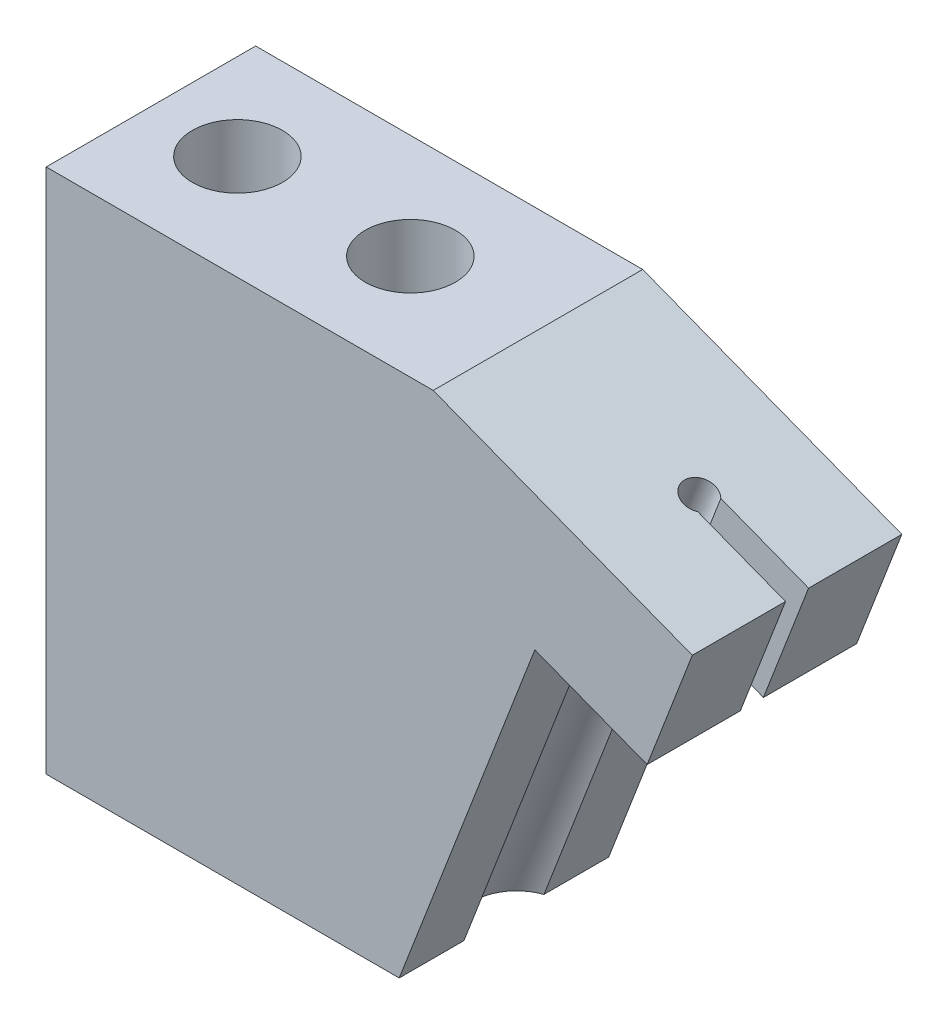
from build123d import *

# Parameters (mm, degrees)
BASE_EXTRUDE_DEPTH                 = 5
CUTAWAY_FOR_CLAMP_PLATE_WIRE_DEPTH = 11
HOLES_TO_PITCH_PLATE_REACH         = 22
SKETCH4_R                          = 2.15265
SKETCH5_R                          = 2.05
EXTRUDE1_DEPTH                     = 4
SKETCH6_R                          = 0.75
EXTRUDE2_DEPTH                     = 2
SKETCH8_W                          = 18.476012794
SKETCH8_H                          = 10
SKETCH8_R                          = 2.15265
EXTRUDE3_DEPTH                     = 5.102995
SKETCH7_R                          = 2.05
CUT_EXTRUDE1_DEPTH                 = 25.066935872
CUT_EXTRUDE3_REACH                 = 32.496
SKETCH12_W                         = 1.1
SKETCH12_H                         = 6
F_8_32_TAPPED_HOLE1_D              = 3.4544
F_8_32_TAPPED_HOLE1_DEPTH          = 6.858
F_8_32_TAPPED_HOLE1_TIP            = 1.037806461


with BuildPart() as part:
    # Sketch1 → Base-Extrude (new body, symmetric)
    with BuildSketch(Plane.XY):
        Polygon((-7.703086391, 2.967740731), (0, 0), (7.703086391, -2.967740731), (1.037503031, -20.268970563), (-25.460082654, -20.268970563), (-25.460082654, -0.268970563), (-8.950082654, -0.268970563), align=None)
    extrude(amount=BASE_EXTRUDE_DEPTH, both=True)

    # Sketch2 → Cutaway for Clamp Plate & Wire (cut, through all)
    with BuildSketch(Plane.XY.offset(5)):
        Polygon((-7.703086391, 2.967740731), (7.703086391, -2.967740731), (1.037503031, -20.268970563), (-8.607332328, -20.268970563), (-2.133223778, -3.464733945), (-9.141119453, -0.764826872), align=None)
    extrude(amount=-CUTAWAY_FOR_CLAMP_PLATE_WIRE_DEPTH, mode=Mode.SUBTRACT)

    # Sketch4 → Holes to Pitch Plate (cut, up to next)
    with BuildSketch(Plane(origin=(0, -0.268970563, 0), x_dir=(-1, 0, 0), z_dir=(0, 1, 0)), mode=Mode.PRIVATE) as holes_to_pitch_plate_sk1:
        with Locations((21.332582654, 0)):
            Circle(SKETCH4_R)
    holes_to_pitch_plate_tool1 = extrude(holes_to_pitch_plate_sk1.sketch, amount=-HOLES_TO_PITCH_PLATE_REACH, mode=Mode.PRIVATE) & part.part
    add(holes_to_pitch_plate_tool1.solids().sort_by_distance((-21.332583, -0.268971, 0))[0], mode=Mode.SUBTRACT)
    # Sketch4 → Holes to Pitch Plate (cut, up to next)
    with BuildSketch(Plane(origin=(0, -0.268970563, 0), x_dir=(-1, 0, 0), z_dir=(0, 1, 0)), mode=Mode.PRIVATE) as holes_to_pitch_plate_sk2:
        with Locations(Location((13.077582654, 0, 0), (0, 0, 90))):  # turned: the seam where the file's is
            Circle(SKETCH4_R)
    holes_to_pitch_plate_tool2 = extrude(holes_to_pitch_plate_sk2.sketch, amount=-HOLES_TO_PITCH_PLATE_REACH, mode=Mode.PRIVATE) & part.part
    add(holes_to_pitch_plate_tool2.solids().sort_by_distance((-13.077583, -0.268971, 0))[0], mode=Mode.SUBTRACT)

    # Sketch5 → Extrude1 (add)
    with BuildSketch(Plane(origin=(-1.438033062, -3.732567603, 0), x_dir=(-0.933141901, 0.359508265, 0), z_dir=(0.359508265, 0.933141901, 0))):
        Polygon((8.255, 5), (0, 5), (-5, 5), (-5, -5), (0, -5), (8.255, -5), align=None)
        with Locations(Location((0, 0, 0), (0, 0, 291.310049103))):  # turned: the seam where the file's is
            Circle(SKETCH5_R, mode=Mode.SUBTRACT)
    extrude(amount=EXTRUDE1_DEPTH)

    # Sketch6 → Extrude2 (add)
    with BuildSketch(Plane(origin=(0, 0, 0), x_dir=(-0.933141901, 0.359508265, 0), z_dir=(0.359508265, 0.933141901, 0))):
        Polygon((0, 5), (8.255, 5), (8.255, -5), (0, -5), (-5, -5), (-5, 5), align=None)
        Circle(SKETCH6_R, mode=Mode.SUBTRACT)
    extrude(amount=EXTRUDE2_DEPTH)

    # Sketch8 → Extrude3 (add)
    with BuildSketch(Plane(origin=(0, -0.268970563, 0), x_dir=(-1, 0, 0), z_dir=(0, 1, 0))):
        with Locations((16.222076257, 0)):
            Rectangle(SKETCH8_W, SKETCH8_H)
        with Locations(Location((21.332582654, 0, 0), (0, 0, 90))):  # turned: the seam where the file's is
            Circle(SKETCH8_R, mode=Mode.SUBTRACT)
        with Locations(Location((13.077582654, 0, 0), (0, 0, 90))):  # turned: the seam where the file's is
            Circle(SKETCH8_R, mode=Mode.SUBTRACT)
    extrude(amount=EXTRUDE3_DEPTH)

    # Sketch7 → Cut-Extrude1 (cut, through all)
    with BuildSketch(Plane(origin=(-1.438033062, -3.732567603, 0), x_dir=(0.933141901, -0.359508265, 0), z_dir=(-0.359508265, -0.933141901, 0))):
        with Locations(Location((0, 0, 0), (0, 0, 248.689950897))):  # turned: the seam where the file's is
            Circle(SKETCH7_R)
    extrude(amount=CUT_EXTRUDE1_DEPTH, mode=Mode.SUBTRACT)

    # Sketch12 → Cut-Extrude3 (cut, up to next)
    with BuildSketch(Plane(origin=(4.665709504, -1.797541327, 0), x_dir=(0, 0, -1), z_dir=(0.933141901, -0.359508265, 0)), mode=Mode.PRIVATE) as cut_extrude3_sk1:
        with Locations((0, -1)):
            Rectangle(SKETCH12_W, SKETCH12_H)
    cut_extrude3_tool1 = extrude(cut_extrude3_sk1.sketch, amount=-CUT_EXTRUDE3_REACH, mode=Mode.PRIVATE) & part.part
    add(cut_extrude3_tool1.solids().sort_by_distance((4.306201, -2.730683, 0))[0], mode=Mode.SUBTRACT)

    # #8-32 Tapped Hole1
    with Locations(Plane(origin=(-0.695190716, 0.267833658, 0), x_dir=(0, 0, -1), z_dir=(0.933141901, -0.359508265, 0))):
        with Locations((-0.041026912, -7.429)):
            Hole(F_8_32_TAPPED_HOLE1_D / 2, depth=F_8_32_TAPPED_HOLE1_DEPTH)
            with Locations((0, 0, -(F_8_32_TAPPED_HOLE1_DEPTH + F_8_32_TAPPED_HOLE1_TIP / 2))):  # 118° drill point
                Cone(0, F_8_32_TAPPED_HOLE1_D / 2, F_8_32_TAPPED_HOLE1_TIP, mode=Mode.SUBTRACT)


solid = part.part
